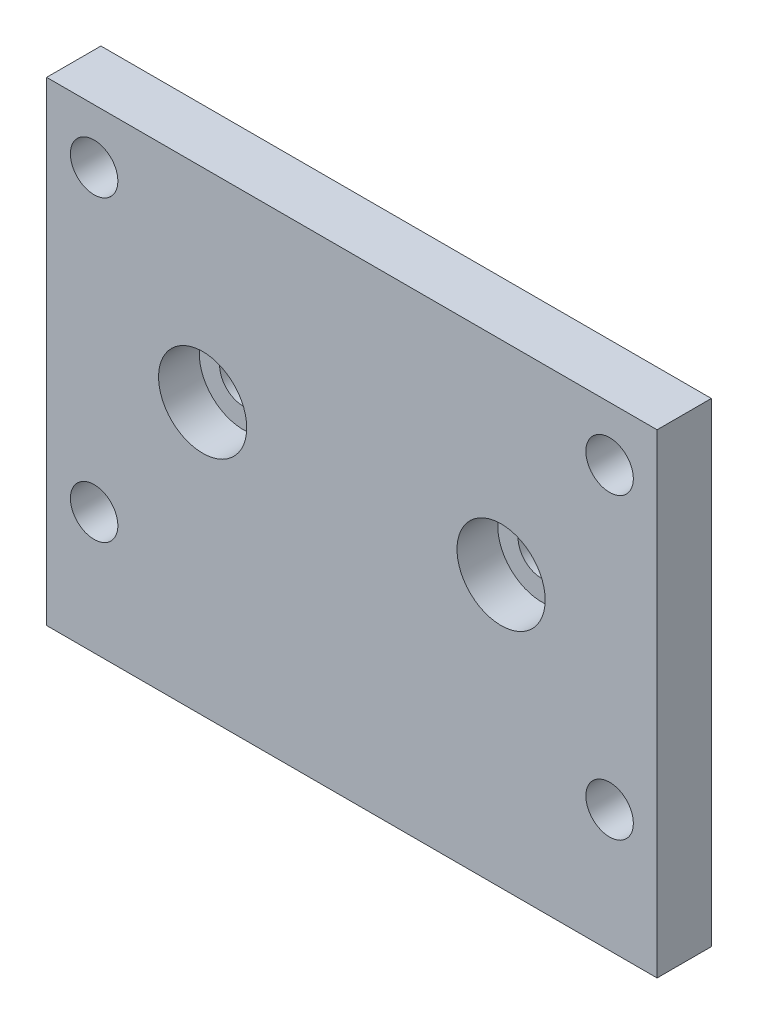
from build123d import *

# Parameters (mm, degrees)
SKETCH_1_W          = 45
SKETCH_1_H          = 35
EXTRUDE_1_DEPTH     = 4
SKETCH_2_R          = 1.75
CUT_EXTRUDE_1_DEPTH = 5
SKETCH_3_R          = 3.25
CUT_EXTRUDE_2_DEPTH = 3


with BuildPart() as part:
    # ｽｹｯﾁ1 → ﾎﾞｽ - 押し出し1 (new body)
    with BuildSketch(Plane.XY):
        Rectangle(SKETCH_1_W, SKETCH_1_H)
    extrude(amount=EXTRUDE_1_DEPTH)

    # ｽｹｯﾁ2 → ｶｯﾄ - 押し出し1 (cut, through all)
    with BuildSketch(Plane.XY.offset(4)):
        with Locations((-19, 13.5)):
            Circle(SKETCH_2_R)
        with Locations((-19, -8.5)):
            Circle(SKETCH_2_R)
        with Locations((19, 13.5)):
            Circle(SKETCH_2_R)
        with Locations((19, -8.5)):
            Circle(SKETCH_2_R)
        with Locations((-11, 2.5)):
            Circle(SKETCH_2_R)
        with Locations((11, 2.5)):
            Circle(SKETCH_2_R)
    extrude(amount=-CUT_EXTRUDE_1_DEPTH, mode=Mode.SUBTRACT)

    # ｽｹｯﾁ3 → ｶｯﾄ - 押し出し2 (cut)
    with BuildSketch(Plane.XY.offset(4)):
        with Locations((-11, 2.5)):
            Circle(SKETCH_3_R)
        with Locations((11, 2.5)):
            Circle(SKETCH_3_R)
    extrude(amount=-CUT_EXTRUDE_2_DEPTH, mode=Mode.SUBTRACT)


solid = part.part
